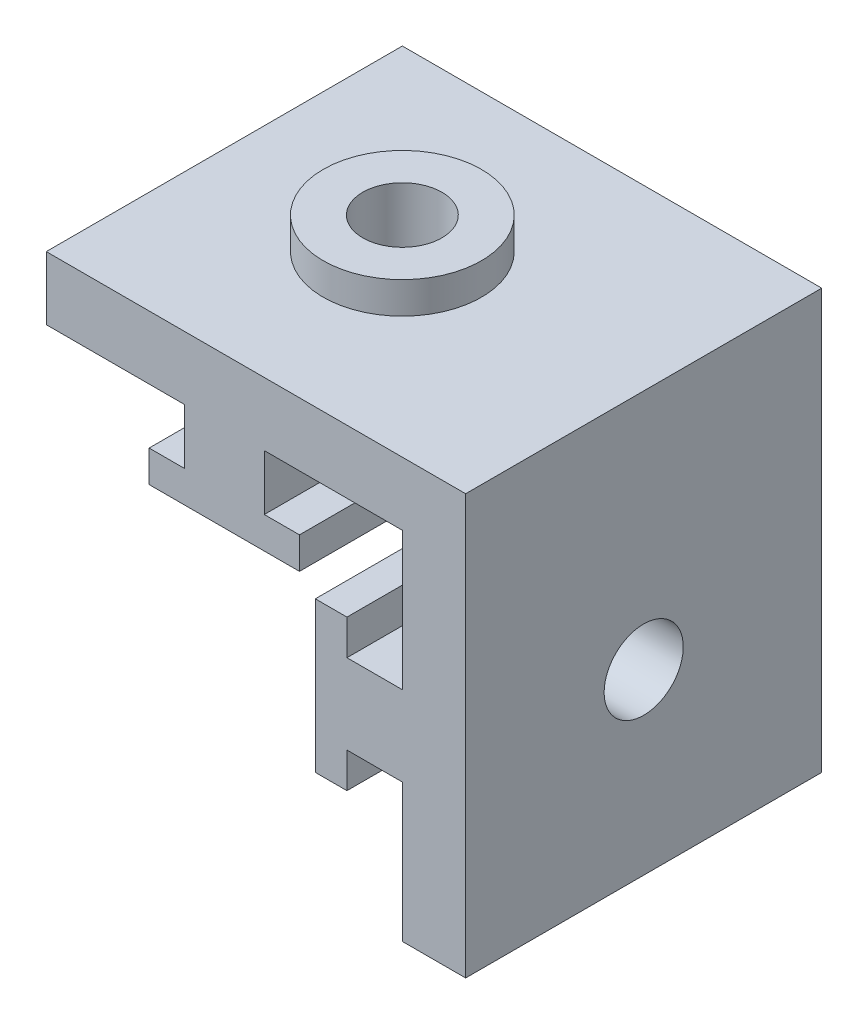
from build123d import *

# Parameters (mm, degrees)
BOSS_EXTRU_1_DEPTH      = 45
ENL_V_MAT_EXTRU_1_REACH = 55
ESQUISSE2_R             = 5
ENL_V_START             = -12.5
ESQUISSE3_W             = 37.334250657
ESQUISSE3_H             = 36.0198364
ENL_V_MAT_EXTRU_2_DEPTH = 20
ESQUISSE4_R             = 10
BOSS_EXTRU_2_DEPTH      = 4
ENL_V_MAT_EXTRU_3_REACH = 59
ESQUISSE5_R             = 5


with BuildPart() as part:
    # Esquisse1 → Boss.-Extru.1 (new body)
    with BuildSketch(Plane.XY):
        Polygon((-53, 0), (0, 0), (0, -53), (-8, -53), (-8, -35.552659183), (-15, -35.552659183), (-15, -40), (-19, -40), (-19, -21), (-15, -21), (-15, -25.447340817), (-8, -25.447340817), (-8, -8), (-25.447340817, -8), (-25.447340817, -15), (-21, -15), (-21, -19), (-40, -19), (-40, -15), (-35.552659183, -15), (-35.552659183, -8), (-53, -8), align=None)
    extrude(amount=BOSS_EXTRU_1_DEPTH)

    # Esquisse2 → Enlèv. mat.-Extru.1 (cut, up to next)
    with BuildSketch(Plane(origin=(0, 0, 0), x_dir=(0, 0, -1), z_dir=(1, 0, 0)), mode=Mode.PRIVATE) as enl_v_mat_extru_1_sk1:
        with Locations((-22.5, -30.5)):
            Circle(ESQUISSE2_R)
    enl_v_mat_extru_1_tool1 = extrude(enl_v_mat_extru_1_sk1.sketch, amount=-ENL_V_MAT_EXTRU_1_REACH, mode=Mode.PRIVATE) & part.part
    add(enl_v_mat_extru_1_tool1.solids().sort_by_distance((0, -30.5, 22.5))[0], mode=Mode.SUBTRACT)

    # Esquisse3 → Enlèv. mat.-Extru.2 (cut)
    with BuildSketch(Plane(origin=(0, 0, 0), x_dir=(-1, 0, 0), z_dir=(0, 0, -1)).offset(ENL_V_START)):
        with Locations((26.667125329, -26.0099182)):
            Rectangle(ESQUISSE3_W, ESQUISSE3_H)
    extrude(amount=-ENL_V_MAT_EXTRU_2_DEPTH, mode=Mode.SUBTRACT)

    # Esquisse4 → Boss.-Extru.2 (add)
    with BuildSketch(Plane(origin=(0, 0, 0), x_dir=(1, 0, 0), z_dir=(0, 1, 0))):
        with Locations((-30.5, -22.5)):
            Circle(ESQUISSE4_R)
    extrude(amount=BOSS_EXTRU_2_DEPTH)

    # Esquisse5 → Enlèv. mat.-Extru.3 (cut, up to next)
    with BuildSketch(Plane(origin=(0, 4, 0), x_dir=(1, 0, 0), z_dir=(0, 1, 0)), mode=Mode.PRIVATE) as enl_v_mat_extru_3_sk1:
        with Locations((-30.5, -22.5)):
            Circle(ESQUISSE5_R)
    enl_v_mat_extru_3_tool1 = extrude(enl_v_mat_extru_3_sk1.sketch, amount=-ENL_V_MAT_EXTRU_3_REACH, mode=Mode.PRIVATE) & part.part
    add(enl_v_mat_extru_3_tool1.solids().sort_by_distance((-30.5, 4, 22.5))[0], mode=Mode.SUBTRACT)


solid = part.part
